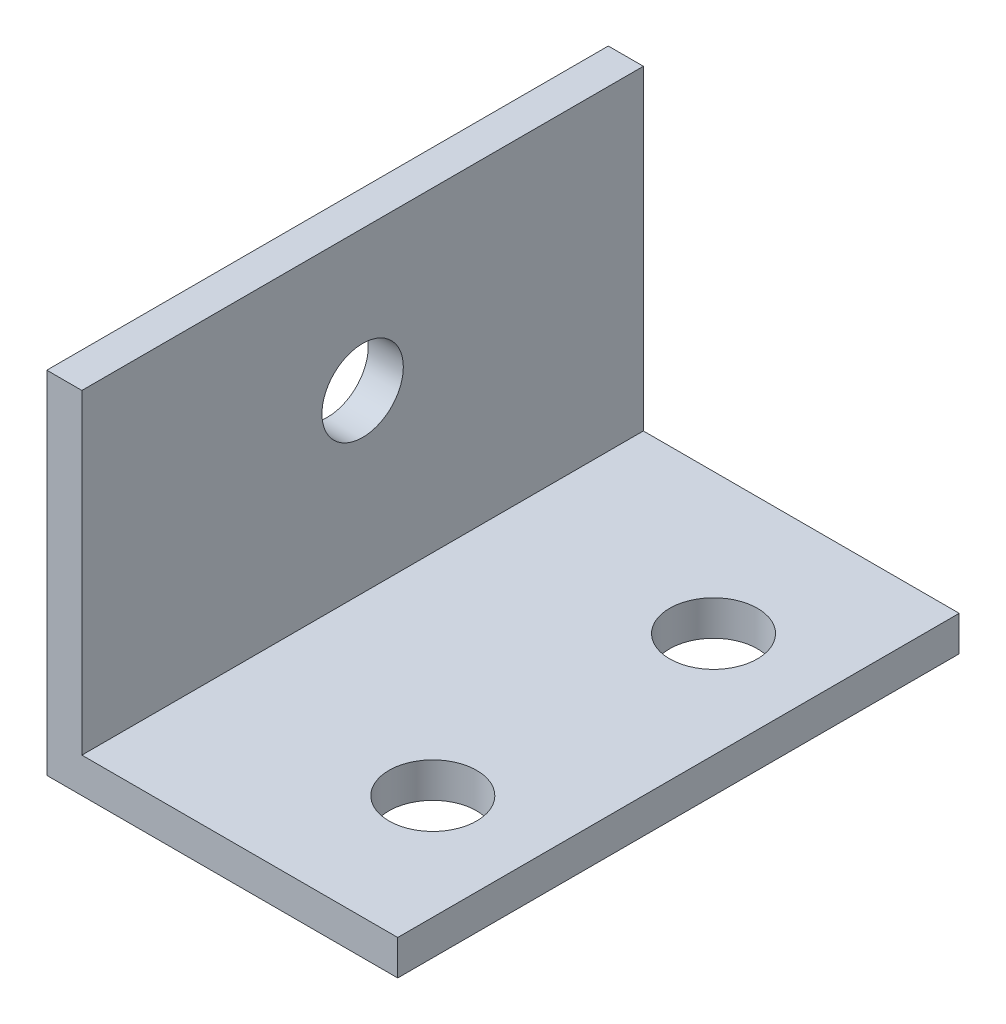
from build123d import *

# Parameters (mm, degrees)
SKETCH1_W           = 3.175
SKETCH1_H           = 31.75
SKETCH1_W_2         = 28.575
SKETCH1_H_2         = 3.175
BOSS_EXTRUDE1_DEPTH = 50.8
POT_MOUNT_REACH     = 5.175
SKETCH2_R           = 3.683
BASE_MOUNT_REACH    = 5.175
SKETCH3_R           = 3.96875


with BuildPart() as part:
    # Sketch1 → Boss-Extrude1 (new body)
    with BuildSketch(Plane.XY):
        with Locations((1.5875, 15.875)):
            Rectangle(SKETCH1_W, SKETCH1_H)
        with Locations((17.4625, 1.5875)):
            Rectangle(SKETCH1_W_2, SKETCH1_H_2)
    extrude(amount=BOSS_EXTRUDE1_DEPTH)

    # Sketch2 → Pot Mount (cut, up to next)
    with BuildSketch(Plane(origin=(3.175, 0, 0), x_dir=(0, 0, -1), z_dir=(1, 0, 0)), mode=Mode.PRIVATE) as pot_mount_sk1:
        with Locations((-25.4, 19.05)):
            Circle(SKETCH2_R)
    pot_mount_tool1 = extrude(pot_mount_sk1.sketch, amount=-POT_MOUNT_REACH, mode=Mode.PRIVATE) & part.part
    add(pot_mount_tool1.solids().sort_by_distance((3.175, 19.05, 25.4))[0], mode=Mode.SUBTRACT)

    # Sketch3 → Base Mount (cut, up to next)
    with BuildSketch(Plane(origin=(0, 3.175, 0), x_dir=(1, 0, 0), z_dir=(0, 1, 0)), mode=Mode.PRIVATE) as base_mount_sk1:
        with Locations((22.225, -38.1)):
            Circle(SKETCH3_R)
    base_mount_tool1 = extrude(base_mount_sk1.sketch, amount=-BASE_MOUNT_REACH, mode=Mode.PRIVATE) & part.part
    add(base_mount_tool1.solids().sort_by_distance((22.225, 3.175, 38.1))[0], mode=Mode.SUBTRACT)
    # Sketch3 → Base Mount (cut, up to next)
    with BuildSketch(Plane(origin=(0, 3.175, 0), x_dir=(1, 0, 0), z_dir=(0, 1, 0)), mode=Mode.PRIVATE) as base_mount_sk2:
        with Locations((22.225, -12.7)):
            Circle(SKETCH3_R)
    base_mount_tool2 = extrude(base_mount_sk2.sketch, amount=-BASE_MOUNT_REACH, mode=Mode.PRIVATE) & part.part
    add(base_mount_tool2.solids().sort_by_distance((22.225, 3.175, 12.7))[0], mode=Mode.SUBTRACT)


solid = part.part
